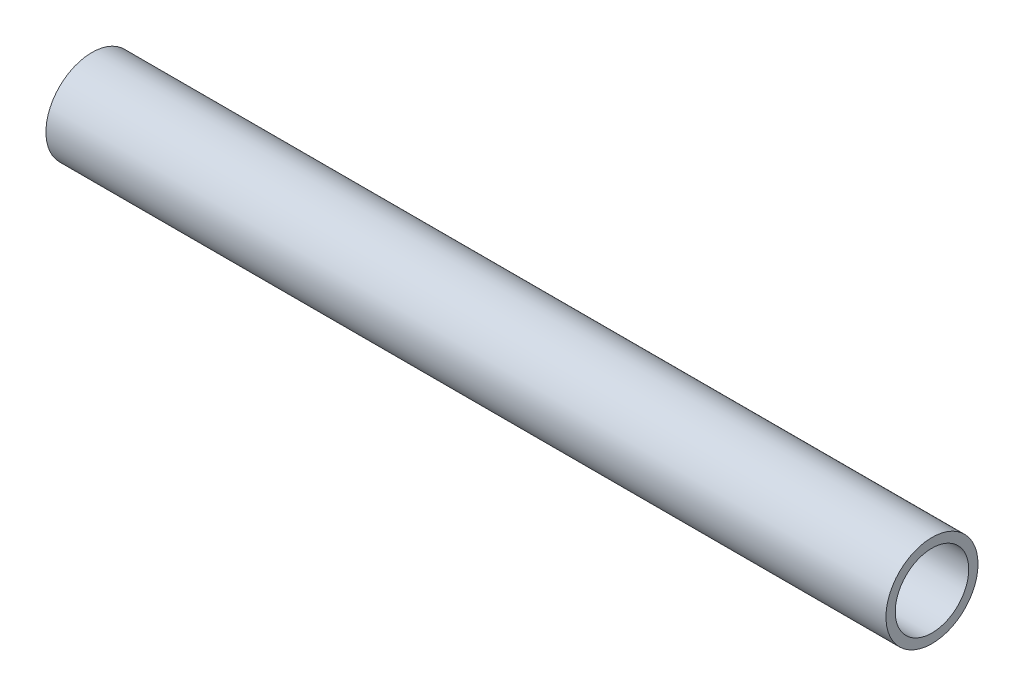
from build123d import *

# Parameters (mm, degrees)
SKETCH1_R           = 16.7005
SKETCH1_R_2         = 13.335
BOSS_EXTRUDE1_DEPTH = 304.8


with BuildPart() as part:
    # Sketch1 → Boss-Extrude1 (new body)
    with BuildSketch(Plane(origin=(0, 0, 0), x_dir=(0, 0, -1), z_dir=(1, 0, 0))):
        Circle(SKETCH1_R)
        Circle(SKETCH1_R_2, mode=Mode.SUBTRACT)
    extrude(amount=BOSS_EXTRUDE1_DEPTH)


solid = part.part
